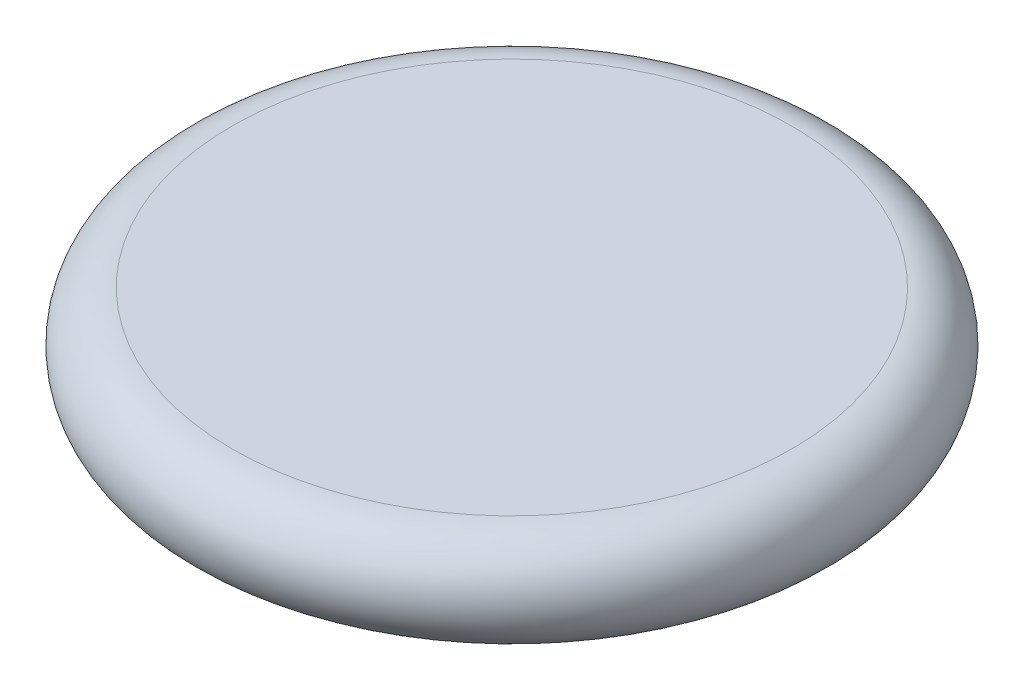
from build123d import *


with BuildPart() as part:
    # Эскиз1 → Повернуть1 (revolve)
    with BuildSketch(Plane.XY):
        with BuildLine():
            Line((65.819874197, 11.723568229), (0, 11.723568229))
            Line((0, 11.723568229), (0, -11.723568229))
            Line((0, -11.723568229), (65.819874197, -11.723568229))
            ThreePointArc((65.819874197, -11.723568229), (77.543442427, 0), (65.819874197, 11.723568229))
        make_face()
    revolve(axis=Axis((0, 37.699950899, 0), (0, -1, 0)))


solid = part.part
